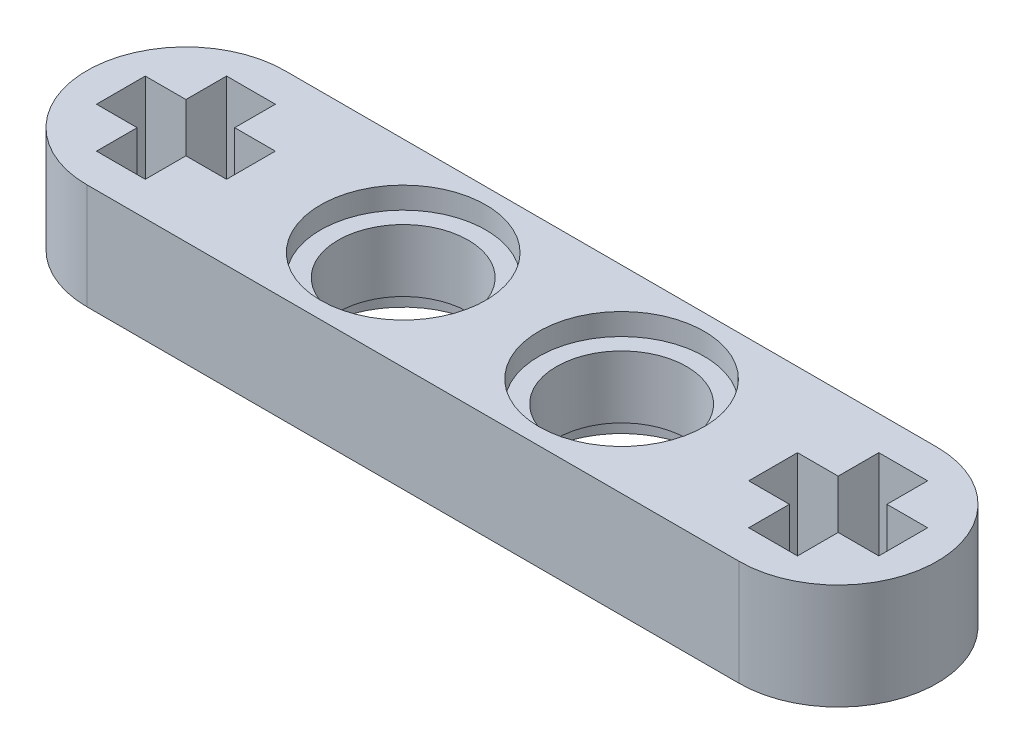
from build123d import *

# Parameters (mm, degrees)
SKETCH1_R           = 2.4
BOSS_EXTRUDE1_DEPTH = 3.9
SKETCH2_R           = 3.05
CUT_EXTRUDE1_DEPTH  = 0.8
SKETCH3_R           = 3.05
CUT_EXTRUDE2_DEPTH  = 0.8


with BuildPart() as part:
    # Sketch1 → Boss-Extrude1 (new body)
    with BuildSketch(Plane(origin=(0, 0, 0), x_dir=(1, 0, 0), z_dir=(0, 1, 0))):
        with BuildLine():
            Line((-12.035, 3.65), (12.035, 3.65))
            ThreePointArc((12.035, 3.65), (15.685, 0), (12.035, -3.65))
            Line((12.035, -3.65), (-12.035, -3.65))
            ThreePointArc((-12.035, -3.65), (-15.685, 0), (-12.035, 3.65))
        make_face()
        with Locations((-4.033060202, 0.018008222)):
            Circle(SKETCH1_R, mode=Mode.SUBTRACT)
        with Locations((4.035, 0.008270612)):
            Circle(SKETCH1_R, mode=Mode.SUBTRACT)
        Polygon((11.135, 2.4), (11.135, 0.9), (9.635, 0.9), (9.635, -0.9), (11.135, -0.9), (11.135, -2.4), (12.935, -2.4), (12.935, -0.9), (14.435, -0.9), (14.435, 0.9), (12.935, 0.9), (12.935, 2.4), align=None, mode=Mode.SUBTRACT)
        Polygon((-12.933060202, 2.401087844), (-12.933060202, 0.901087844), (-14.433060202, 0.901087844), (-14.433060202, -0.898912156), (-12.933060202, -0.898912156), (-12.933060202, -2.398912156), (-11.133060202, -2.398912156), (-11.133060202, -0.898912156), (-9.633060202, -0.898912156), (-9.633060202, 0.901087844), (-11.133060202, 0.901087844), (-11.133060202, 2.401087844), align=None, mode=Mode.SUBTRACT)
    extrude(amount=BOSS_EXTRUDE1_DEPTH)

    # Sketch2 → Cut-Extrude1 (cut)
    with BuildSketch(Plane(origin=(0, 3.9, 0), x_dir=(1, 0, 0), z_dir=(0, 1, 0))):
        with Locations((4.035, 0.008270612)):
            Circle(SKETCH2_R)
        with Locations((-4.033060202, 0.018008222)):
            Circle(SKETCH2_R)
    extrude(amount=-CUT_EXTRUDE1_DEPTH, mode=Mode.SUBTRACT)

    # Sketch3 → Cut-Extrude2 (cut)
    with BuildSketch(Plane(origin=(0, 0, 0), x_dir=(-1, 0, 0), z_dir=(0, -1, 0))):
        with Locations((4.033060202, 0.018008222)):
            Circle(SKETCH3_R)
        with Locations((-4.035, 0.008270612)):
            Circle(SKETCH3_R)
    extrude(amount=-CUT_EXTRUDE2_DEPTH, mode=Mode.SUBTRACT)


solid = part.part
